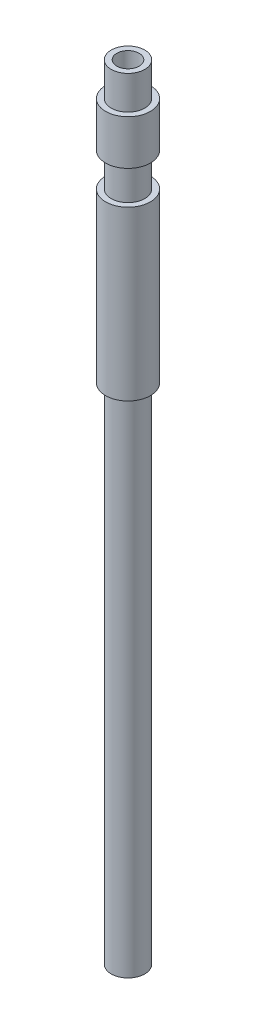
from build123d import *

# Parameters (mm, degrees)
SKETCH_1_R      = 2
SKETCH_1_R_2    = 1
EXTRUDE_1_DEPTH = 70
SKETCH_2_W      = 0.5
SKETCH_2_H      = 3
SKETCH_3_W      = 0.5
SKETCH_3_H      = 45


with BuildPart() as part:
    # Эскиз1 → Бобышка-Вытянуть1 (new body)
    with BuildSketch(Plane(origin=(0, 0, 0), x_dir=(1, 0, 0), z_dir=(0, 1, 0))):
        Circle(SKETCH_1_R)
        Circle(SKETCH_1_R_2, mode=Mode.SUBTRACT)
    extrude(amount=EXTRUDE_1_DEPTH)

    # Эскиз2 → Вырез-Повернуть1 (revolve, cut)
    with BuildSketch(Plane.XY):
        with Locations((1.75, 68.5)):
            Rectangle(SKETCH_2_W, SKETCH_2_H)
        with Locations((1.75, 61.5)):
            Rectangle(SKETCH_2_W, SKETCH_2_H)
    revolve(axis=Axis((0, 70, 0), (0, -1, 0)), mode=Mode.SUBTRACT)

    # Эскиз3 → Вырез-Повернуть2 (revolve, cut)
    with BuildSketch(Plane.XY):
        with Locations((1.75, 22.5)):
            Rectangle(SKETCH_3_W, SKETCH_3_H)
    revolve(axis=Axis((0, 0, 0), (0, 1, 0)), mode=Mode.SUBTRACT)


solid = part.part
